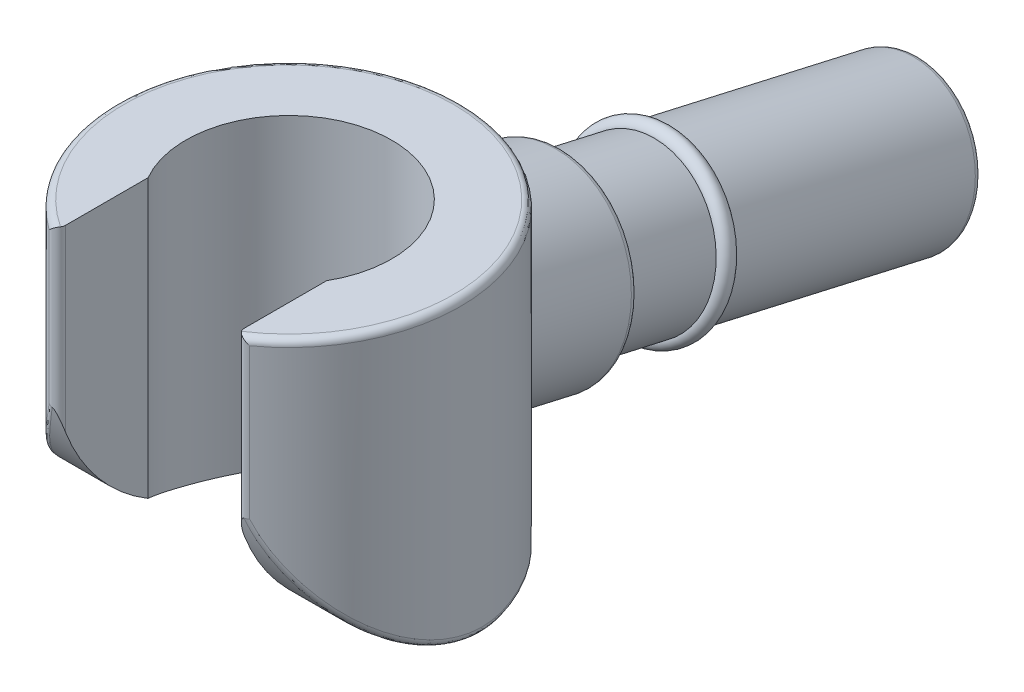
from build123d import *

# Parameters (mm, degrees)
HAND_DEPTH             = 4.45
HAND_CURVE_DEPTH       = 6.683528833
HAND_CURVE_DEPTH_BACK  = 6.683528833
WRIST_REACH            = 13.999
WRIST_END_RADIUS       = 2.5
SKETCH5_R              = 1.125
WRIST_OUTER_REACH      = 19.938
WRIST_OUTER_END_RADIUS = 2.5
WRIST_START            = -5.4
SKETCH6_R              = 1.375
SKETCH7_R              = 0.125
FILLET1_R              = 0.1


with BuildPart() as part:
    # Sketch2 → Hand (new body)
    with BuildSketch(Plane(origin=(0, 0, 0), x_dir=(1, 0, 0), z_dir=(0, 1, 0))):
        with BuildLine():
            Line((-1.3, -2.13541565), (-1.3, -0.748331477))
            ThreePointArc((-1.3, -0.748331477), (0, 1.5), (1.3, -0.748331477))
            Line((1.3, -0.748331477), (1.3, -2.13541565))
            ThreePointArc((1.3, -2.13541565), (0, 2.5), (-1.3, -2.13541565))
        make_face()
    extrude(amount=HAND_DEPTH)

    # Sketch3 → Hand Curve (cut, two sides: drawn at the far end of the back side and taken through both)
    with BuildSketch(Plane(origin=(0, 0, 0), x_dir=(0, 0, -1), z_dir=(1, 0, 0)).offset(-HAND_CURVE_DEPTH_BACK)):
        with BuildLine():
            Line((-2.13541565, 2.85), (-2.13541565, 0))
            Line((-2.13541565, 0), (0.66, 0))
            ThreePointArc((0.66, 0), (-1.319907487, 0.853950861), (-2.13541565, 2.85))
        make_face()
    extrude(amount=HAND_CURVE_DEPTH + HAND_CURVE_DEPTH_BACK, mode=Mode.SUBTRACT)

    # Wrist: up to this cylinder (the profile starts outside it)
    wrist_end = Plane(origin=(0, 0.583887, 0), z_dir=(0, -1, 0)) * Cylinder(WRIST_END_RADIUS, 33.998, mode=Mode.PRIVATE)
    # Sketch5 → Wrist (add, up to the surface)
    with BuildSketch(Plane(origin=(0, 0.583886591, -8.944713292), x_dir=(-1, 0, 0), z_dir=(0, -0.2222292262514004, -0.9749944466506997)), mode=Mode.PRIVATE) as wrist_sk1:
        with Locations(Location((0, 0, 0), (0, 0, 90))):
            Circle(SKETCH5_R)
    wrist_tool1 = extrude(wrist_sk1.sketch, amount=-WRIST_REACH, mode=Mode.PRIVATE) - wrist_end
    add(wrist_tool1.solids().sort_by_distance((0, 0.583887, -8.944713))[0])

    # Wrist Outer: up to this cylinder (the profile starts outside it)
    wrist_outer_end = Plane(origin=(0, 1.783924, 0), z_dir=(0, -1, 0)) * Cylinder(WRIST_OUTER_END_RADIUS, 45.876, mode=Mode.PRIVATE)
    # Sketch6 → Wrist Outer (add, up to the surface)
    with BuildSketch(Plane(origin=(0, -1.909235534, -8.376459183), x_dir=(-1, 0, 0), z_dir=(0, -0.2222292262514004, -0.9749944466506997)).offset(WRIST_START), mode=Mode.PRIVATE) as wrist_outer_sk1:
        with Locations(Location((0, 2.557062897, 0), (0, 0, 90))):
            Circle(SKETCH6_R)
    wrist_outer_tool1 = extrude(wrist_outer_sk1.sketch, amount=-WRIST_OUTER_REACH, mode=Mode.PRIVATE) - wrist_outer_end
    add(wrist_outer_tool1.solids().sort_by_distance((0, 1.783924, -3.679743))[0])

    # Sketch7 → Wrist Ring (revolve)
    with BuildSketch(Plane(origin=(0, 0, 0), x_dir=(0, 0, -1), z_dir=(1, 0, 0)), mode=Mode.PRIVATE) as wrist_ring_sk:
        with Locations((4.944713292, 0.341748704)):
            Circle(SKETCH7_R)
    revolve(wrist_ring_sk.sketch.rotate(Axis((0, 2.052821776, -2.5), (0, -0.22222922625140032, -0.9749944466506997)), 180), axis=Axis((0, 2.052821776, -2.5), (0, -0.22222922625140032, -0.9749944466506997)))

    # Fillet1
    fillet1_edges = [part.edges().sort_by_distance(p)[0] for p in [
        (0, 4.45, -2.5),
        (0, 0, -2.5),
        (2.10253899, 0.887760382, 1.352527188),
        (-2.102538947, 0.887760359, 1.352527185),
        (0, -0.512982162, -8.694705413),
        (0, 0.68705566, -3.429735401),
        (0, 0.642557333, -2.5),
        (0, 0.443307048, -3.374178094),
        (-1.3, 3.65, 2.13541565),
        (1.3, 3.65, 2.13541565),
    ]]
    fillet(fillet1_edges, radius=FILLET1_R)


solid = part.part
